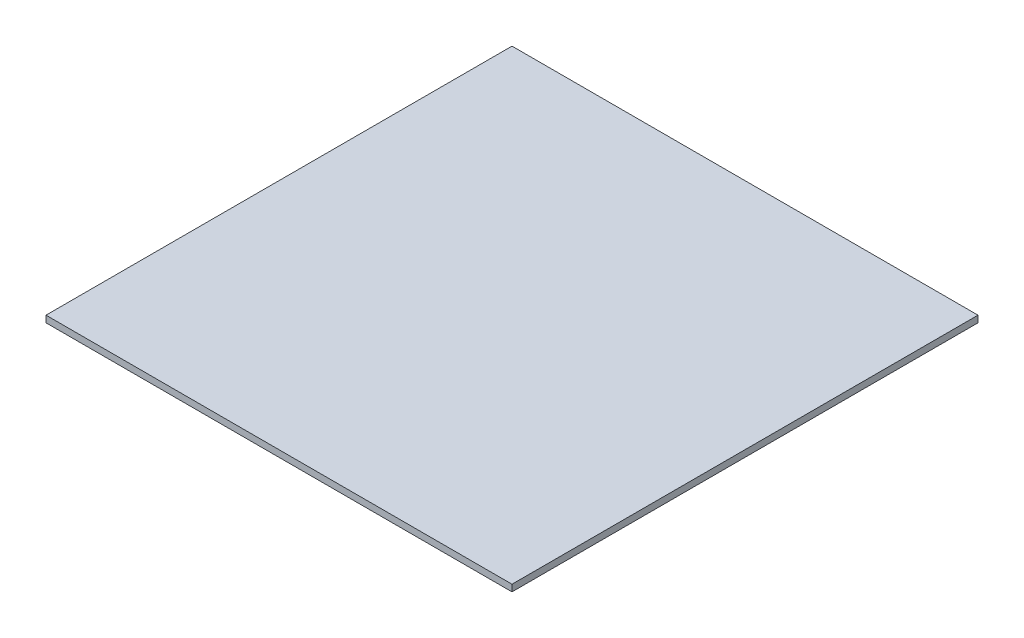
from build123d import *

# Parameters (mm, degrees)
SKETCH1_W           = 889
SKETCH1_H           = 889
BOSS_EXTRUDE1_DEPTH = 12.7


with BuildPart() as part:
    # Sketch1 → Boss-Extrude1 (new body)
    with BuildSketch(Plane(origin=(0, 0, 0), x_dir=(1, 0, 0), z_dir=(0, 1, 0))):
        with Locations((444.5, 444.5)):
            Rectangle(SKETCH1_W, SKETCH1_H)
    extrude(amount=BOSS_EXTRUDE1_DEPTH)


solid = part.part
